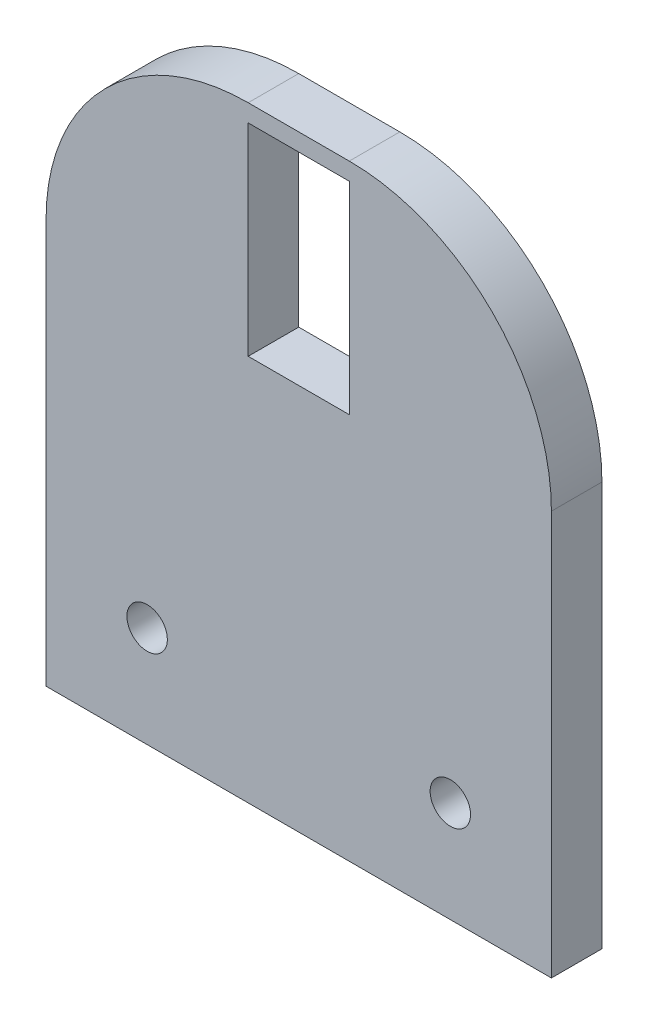
from build123d import *

# Parameters (mm, degrees)
SKETCH1_W           = 50
SKETCH1_H           = 5
BOSS_EXTRUDE1_DEPTH = 60
FILLET1_R           = 20
SKETCH2_R           = 2
SKETCH2_W           = 10
SKETCH2_H           = 20
CUT_EXTRUDE1_DEPTH  = 5


with BuildPart() as part:
    # Sketch1 → Boss-Extrude1 (new body)
    with BuildSketch(Plane(origin=(0, 0, 0), x_dir=(1, 0, 0), z_dir=(0, 1, 0))):
        Rectangle(SKETCH1_W, SKETCH1_H)
    extrude(amount=BOSS_EXTRUDE1_DEPTH)

    # Fillet1
    fillet1_edges = [part.edges().sort_by_distance(p)[0] for p in [
        (25, 60, 0),
        (-25, 60, 0),
    ]]
    fillet(fillet1_edges, radius=FILLET1_R)

    # Sketch2 → Cut-Extrude1 (cut)
    with BuildSketch(Plane.XY.offset(2.5)):
        with Locations((-15, 10)):
            Circle(SKETCH2_R)
        with Locations((15, 10)):
            Circle(SKETCH2_R)
        with Locations((0, 48.271414018)):
            Rectangle(SKETCH2_W, SKETCH2_H)
    extrude(amount=-CUT_EXTRUDE1_DEPTH, mode=Mode.SUBTRACT)


solid = part.part
